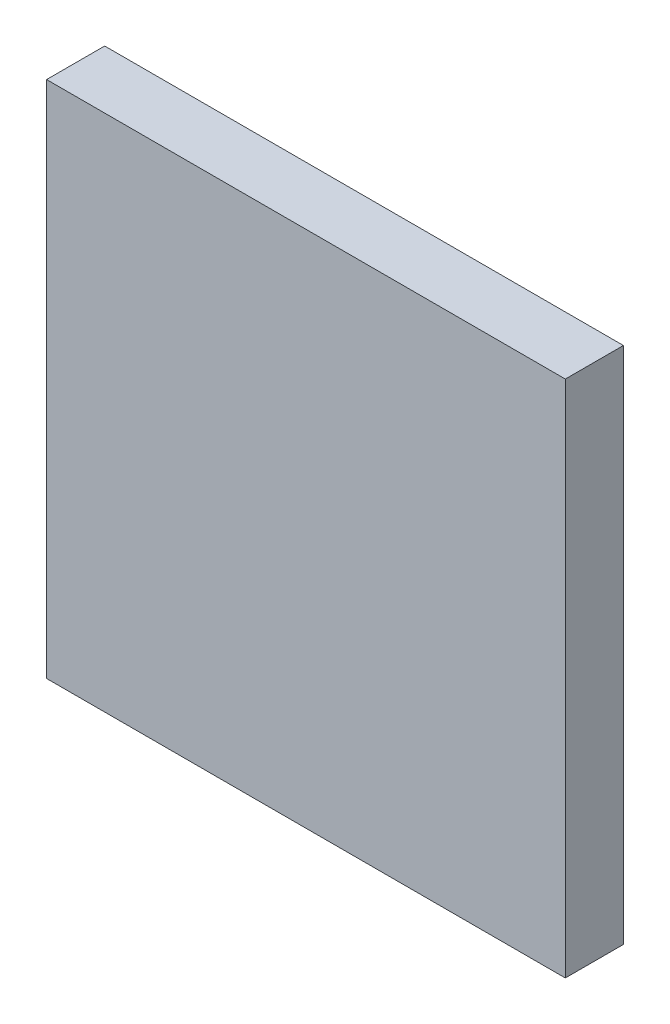
from build123d import *

# Parameters (mm, degrees)
BOSS_EXTRUDE2_DEPTH = 0.635
SKETCH8_W           = 5.67000009
SKETCH8_H           = 5.67000009
BOSS_EXTRUDE5_DEPTH = 0.635


with BuildPart() as part:
    # Sketch7 → Boss-Extrude2 (new body)
    with BuildSketch(Plane.XY):
        Polygon((0.880000018, 0.880000018), (0.880000018, 0), (3.520000072, 0), (3.520000072, 0.880000018), (4.40000009, 0.880000018), (4.40000009, 3.520000072), (3.520000072, 3.520000072), (3.520000072, 4.40000009), (0.880000018, 4.40000009), (0.880000018, 3.520000072), (0, 3.520000072), (0, 0.880000018), align=None)
    extrude(amount=BOSS_EXTRUDE2_DEPTH)

    # Sketch8 → Boss-Extrude5 (add)
    with BuildSketch(Plane.XY.offset(0.635)):
        with Locations((2.200000045, 2.200000045)):
            Rectangle(SKETCH8_W, SKETCH8_H)
    extrude(amount=-BOSS_EXTRUDE5_DEPTH)


solid = part.part
